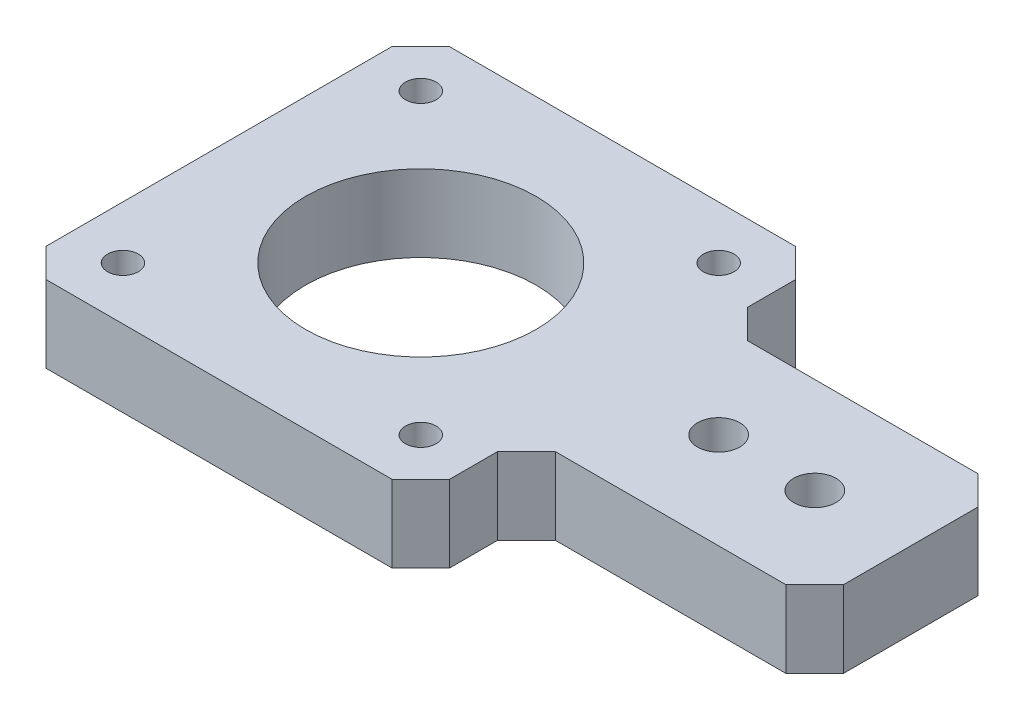
from build123d import *

# Parameters (mm, degrees)
CROQUIS1_R              = 12
CROQUIS1_R_2            = 1.6
CROQUIS1_R_3            = 2.2
SALIENTE_EXTRUIR1_DEPTH = 8


with BuildPart() as part:
    # Croquis1 → Saliente-Extruir1 (new body)
    with BuildSketch(Plane(origin=(0, 0, 0), x_dir=(1, 0, 0), z_dir=(0, 1, 0))):
        Polygon((18, -21), (20.998132752, -18.001867248), (20.998132752, -13.001867248), (23.996265504, -10.003734496), (47.996265504, -10.003734496), (50.994398257, -7.005601743), (50.994398257, 6.994398257), (47.996265504, 9.992531009), (23.996265504, 9.992531009), (20.998132752, 12.990663761), (20.998132752, 17.990663761), (18, 20.988796513), (-18, 20.988796513), (-21.001869571, 17.99439127), (-21.001869571, -18.00560873), (-18, -21), align=None)
        Circle(CROQUIS1_R, mode=Mode.SUBTRACT)
        with Locations((-15.5, -15.5)):
            Circle(CROQUIS1_R_2, mode=Mode.SUBTRACT)
        with Locations((-15.5, 15.5)):
            Circle(CROQUIS1_R_2, mode=Mode.SUBTRACT)
        with Locations((15.5, 15.5)):
            Circle(CROQUIS1_R_2, mode=Mode.SUBTRACT)
        with Locations((15.5, -15.5)):
            Circle(CROQUIS1_R_2, mode=Mode.SUBTRACT)
        with Locations((30.998135075, -0.003734496)):
            Circle(CROQUIS1_R_3, mode=Mode.SUBTRACT)
        with Locations((41.008135075, -0.003734496)):
            Circle(CROQUIS1_R_3, mode=Mode.SUBTRACT)
    extrude(amount=SALIENTE_EXTRUIR1_DEPTH)


solid = part.part
